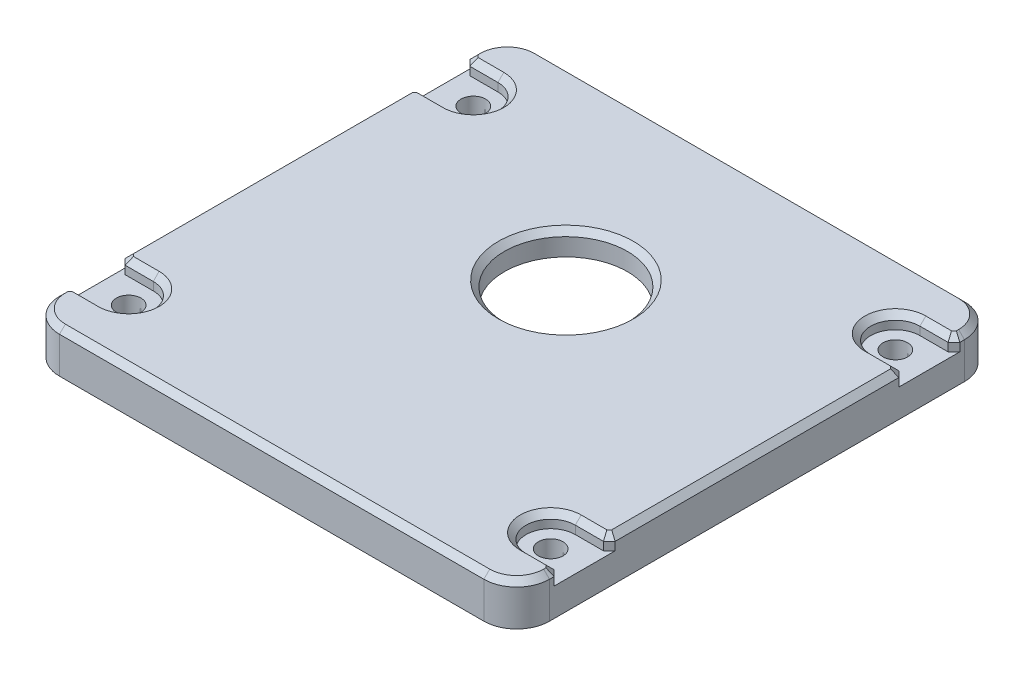
from build123d import *

# Parameters (mm, degrees)
SKETCH1_W           = 41.8
SKETCH1_H           = 41
SKETCH1_W_2         = 36.2
SKETCH1_H_2         = 37.4
BOSS_EXTRUDE1_DEPTH = 3
FILLET1_R           = 2.8
BOSS_EXTRUDE2_DEPTH = 0.6
BOSS_EXTRUDE3_DEPTH = 4.4
SKETCH5_R           = 1.05
CUT_EXTRUDE1_DEPTH  = 5.4
SKETCH6_W           = 31.1
SKETCH6_H           = 1.8
BOSS_EXTRUDE4_DEPTH = 4.4
FILLET2_R           = 1
SKETCH7_W           = 36.2
SKETCH7_H           = 37.4
SKETCH7_W_2         = 36
SKETCH7_H_2         = 37.2
CUT_EXTRUDE2_DEPTH  = 1.4
FILLET3_R           = 0.5
FILLET4_R           = 0.6
SKETCH8_R           = 1.05
SKETCH8_R_2         = 5.25
BOSS_EXTRUDE5_DEPTH = 2
CUT_EXTRUDE3_DEPTH  = 1.2
CHAMFER1_SIZE       = 0.5
CHAMFER2_SIZE       = 0.5


with BuildPart() as part:
    # Sketch1 → Boss-Extrude1 (new body)
    with BuildSketch(Plane(origin=(0, 0, 0), x_dir=(1, 0, 0), z_dir=(0, 1, 0))):
        Rectangle(SKETCH1_W, SKETCH1_H)
        Rectangle(SKETCH1_W_2, SKETCH1_H_2, mode=Mode.SUBTRACT)
    extrude(amount=BOSS_EXTRUDE1_DEPTH)

    # Fillet1
    fillet1_edges = [part.edges().sort_by_distance(p)[0] for p in [
        (20.9, 1.5, 20.5),
        (-20.9, 1.5, 20.5),
        (-20.9, 1.5, -20.5),
        (20.9, 1.5, -20.5),
    ]]
    fillet(fillet1_edges, radius=FILLET1_R)

    # Sketch2 → Boss-Extrude2 (add)
    with BuildSketch(Plane.XZ):
        with BuildLine():
            Line((20.9, -17.7), (20.9, 17.7))
            ThreePointArc((20.9, 17.7), (20.079898987, 19.679898987), (18.1, 20.5))
            Line((18.1, 20.5), (-18.1, 20.5))
            ThreePointArc((-18.1, 20.5), (-20.079898987, 19.679898987), (-20.9, 17.7))
            Line((-20.9, 17.7), (-20.9, -17.7))
            ThreePointArc((-20.9, -17.7), (-20.079898987, -19.679898987), (-18.1, -20.5))
            Line((-18.1, -20.5), (18.1, -20.5))
            ThreePointArc((18.1, -20.5), (20.079898987, -19.679898987), (20.9, -17.7))
        make_face()
        with BuildLine():
            Line((20.1, -17.7), (20.1, 17.7))
            ThreePointArc((20.1, 17.7), (19.514213562, 19.114213562), (18.1, 19.7))
            Line((18.1, 19.7), (-18.1, 19.7))
            ThreePointArc((-18.1, 19.7), (-19.514213562, 19.114213562), (-20.1, 17.7))
            Line((-20.1, 17.7), (-20.1, -17.7))
            ThreePointArc((-20.1, -17.7), (-19.514213562, -19.114213562), (-18.1, -19.7))
            Line((-18.1, -19.7), (18.1, -19.7))
            ThreePointArc((18.1, -19.7), (19.514213562, -19.114213562), (20.1, -17.7))
        make_face(mode=Mode.SUBTRACT)
    extrude(amount=BOSS_EXTRUDE2_DEPTH)

    # Sketch4 → Boss-Extrude3 (add)
    with BuildSketch(Plane(origin=(0, 3, 0), x_dir=(1, 0, 0), z_dir=(0, 1, 0))):
        with BuildLine():
            Line((-18, 15.75), (-18.1, 15.75))
            Line((-18.1, 15.75), (-18.1, 18.7))
            Line((-18.1, 18.7), (-15.55, 18.7))
            Line((-15.55, 18.7), (-15.55, 14.7))
            ThreePointArc((-15.55, 14.7), (-16.267588386, 12.967588386), (-18, 12.25))
            Line((-18, 12.25), (-18.1, 12.25))
            Line((-18.1, 12.25), (-18.1, 13.65))
            Line((-18.1, 13.65), (-18, 13.65))
            ThreePointArc((-18, 13.65), (-16.95, 14.7), (-18, 15.75))
        make_face()
        with BuildLine():
            Line((18.1, 15.75), (18.1, 18.7))
            Line((18.1, 18.7), (15.55, 18.7))
            Line((15.55, 18.7), (15.55, 14.7))
            ThreePointArc((15.55, 14.7), (16.267588386, 12.967588386), (18, 12.25))
            Line((18, 12.25), (18.1, 12.25))
            Line((18.1, 12.25), (18.1, 13.65))
            Line((18.1, 13.65), (18, 13.65))
            ThreePointArc((18, 13.65), (16.95, 14.7), (18, 15.75))
            Line((18, 15.75), (18.1, 15.75))
        make_face()
        with BuildLine():
            Line((18, -15.75), (18.1, -15.75))
            Line((18.1, -15.75), (18.1, -18.7))
            Line((18.1, -18.7), (15.55, -18.7))
            Line((15.55, -18.7), (15.55, -14.7))
            ThreePointArc((15.55, -14.7), (16.267588386, -12.967588386), (18, -12.25))
            Line((18, -12.25), (18.1, -12.25))
            Line((18.1, -12.25), (18.1, -13.65))
            Line((18.1, -13.65), (18, -13.65))
            ThreePointArc((18, -13.65), (16.95, -14.7), (18, -15.75))
        make_face()
        with BuildLine():
            Line((-18.1, -15.75), (-18.1, -18.7))
            Line((-18.1, -18.7), (-15.55, -18.7))
            Line((-15.55, -18.7), (-15.55, -14.7))
            ThreePointArc((-15.55, -14.7), (-16.267588386, -12.967588386), (-18, -12.25))
            Line((-18, -12.25), (-18.1, -12.25))
            Line((-18.1, -12.25), (-18.1, -13.65))
            Line((-18.1, -13.65), (-18, -13.65))
            ThreePointArc((-18, -13.65), (-16.95, -14.7), (-18, -15.75))
            Line((-18, -15.75), (-18.1, -15.75))
        make_face()
    extrude(amount=-BOSS_EXTRUDE3_DEPTH)

    # Sketch5 → Cut-Extrude1 (cut, through all)
    with BuildSketch(Plane(origin=(0, 3, 0), x_dir=(1, 0, 0), z_dir=(0, 1, 0))):
        with Locations((-18, 14.7)):
            Circle(SKETCH5_R)
        with Locations((18, 14.7)):
            Circle(SKETCH5_R)
        with Locations((18, -14.7)):
            Circle(SKETCH5_R)
        with Locations((-18, -14.7)):
            Circle(SKETCH5_R)
    extrude(amount=-CUT_EXTRUDE1_DEPTH, mode=Mode.SUBTRACT)

    # Sketch6 → Boss-Extrude4 (add)
    with BuildSketch(Plane(origin=(0, 3, 0), x_dir=(1, 0, 0), z_dir=(0, 1, 0))):
        with Locations((0, -17.8)):
            Rectangle(SKETCH6_W, SKETCH6_H)
        with Locations((0, 17.8)):
            Rectangle(SKETCH6_W, SKETCH6_H)
        with BuildLine():
            Line((-18.1, 12.25), (-18, 12.25))
            ThreePointArc((-18, 12.25), (-16.267588386, 12.967588386), (-15.55, 14.7))
            Line((-15.55, 14.7), (-15.55, 11.25))
            Line((-15.55, 11.25), (-18.1, 11.25))
            Line((-18.1, 11.25), (-18.1, 12.25))
        make_face()
        with BuildLine():
            Line((-15.55, -11.25), (-18.1, -11.25))
            Line((-18.1, -11.25), (-18.1, -12.25))
            Line((-18.1, -12.25), (-18, -12.25))
            ThreePointArc((-18, -12.25), (-16.267588386, -12.967588386), (-15.55, -14.7))
            Line((-15.55, -14.7), (-15.55, -11.25))
        make_face()
        with BuildLine():
            Line((15.55, -14.7), (15.55, -11.25))
            Line((15.55, -11.25), (18.1, -11.25))
            Line((18.1, -11.25), (18.1, -12.25))
            Line((18.1, -12.25), (18, -12.25))
            ThreePointArc((18, -12.25), (16.267588386, -12.967588386), (15.55, -14.7))
        make_face()
        with BuildLine():
            Line((15.55, 11.25), (18.1, 11.25))
            Line((18.1, 11.25), (18.1, 12.25))
            Line((18.1, 12.25), (18, 12.25))
            ThreePointArc((18, 12.25), (16.267588386, 12.967588386), (15.55, 14.7))
            Line((15.55, 14.7), (15.55, 11.25))
        make_face()
    extrude(amount=-BOSS_EXTRUDE4_DEPTH)

    # Fillet2
    fillet2_edges = [part.edges().sort_by_distance(p)[0] for p in [
        (15.55, 0.8, 16.9),
        (-15.55, 0.8, 16.9),
        (15.55, 0.8, -16.9),
        (-15.55, 0.8, -16.9),
        (-15.55, 0.8, 11.25),
        (-15.55, 0.8, -11.25),
        (15.55, 0.8, 11.25),
        (15.55, 0.8, -11.25),
    ]]
    fillet(fillet2_edges, radius=FILLET2_R)

    # Sketch7 → Cut-Extrude2 (cut)
    with BuildSketch(Plane.XZ.offset(1.4)):
        Rectangle(SKETCH7_W, SKETCH7_H)
        Rectangle(SKETCH7_W_2, SKETCH7_H_2, mode=Mode.SUBTRACT)
    extrude(amount=-CUT_EXTRUDE2_DEPTH, mode=Mode.SUBTRACT)

    # Fillet3
    fillet3_edges = [part.edges().sort_by_distance(p)[0] for p in [
        (-18, -0.7, -13.65),
        (-18, -0.7, -15.75),
        (18, -0.7, -15.75),
        (18, -0.7, -13.65),
        (18, -0.7, 13.65),
        (18, -0.7, 15.75),
        (-18, -0.7, 15.75),
        (-18, -0.7, 13.65),
        (18, -0.7, -11.25),
        (-18, -0.7, -11.25),
        (-18, -0.7, 18.6),
        (-18, -0.7, 11.25),
        (18, -0.7, -18.6),
        (18, -0.7, 11.25),
        (18, -0.7, 18.6),
        (-18, -0.7, -18.6),
    ]]
    fillet(fillet3_edges, radius=FILLET3_R)

    # Fillet4
    fillet4_edges = [part.edges().sort_by_distance(p)[0] for p in [
        (18.1, 1.5, -11.25),
        (-18.1, 1.5, -11.25),
        (-18.1, 1.5, 11.25),
        (18.1, 1.5, 11.25),
    ]]
    fillet(fillet4_edges, radius=FILLET4_R)

    # Sketch8 → Boss-Extrude5 (add)
    with BuildSketch(Plane(origin=(0, 3, 0), x_dir=(1, 0, 0), z_dir=(0, 1, 0))):
        with BuildLine():
            Line((-18.1, -20.5), (18.1, -20.5))
            ThreePointArc((18.1, -20.5), (20.079898987, -19.679898987), (20.9, -17.7))
            Line((20.9, -17.7), (20.9, 17.7))
            ThreePointArc((20.9, 17.7), (20.079898987, 19.679898987), (18.1, 20.5))
            Line((18.1, 20.5), (-18.1, 20.5))
            ThreePointArc((-18.1, 20.5), (-20.079898987, 19.679898987), (-20.9, 17.7))
            Line((-20.9, 17.7), (-20.9, -17.7))
            ThreePointArc((-20.9, -17.7), (-20.079898987, -19.679898987), (-18.1, -20.5))
        make_face()
        with Locations((-18, 14.7)):
            Circle(SKETCH8_R, mode=Mode.SUBTRACT)
        with Locations((18, 14.7)):
            Circle(SKETCH8_R, mode=Mode.SUBTRACT)
        with Locations((18, -14.7)):
            Circle(SKETCH8_R, mode=Mode.SUBTRACT)
        with Locations((-18, -14.7)):
            Circle(SKETCH8_R, mode=Mode.SUBTRACT)
        with Locations((0, 4.6)):
            Circle(SKETCH8_R_2, mode=Mode.SUBTRACT)
    extrude(amount=-BOSS_EXTRUDE5_DEPTH)

    # Sketch9 → Cut-Extrude3 (cut)
    with BuildSketch(Plane(origin=(0, 3, 0), x_dir=(1, 0, 0), z_dir=(0, 1, 0))):
        with BuildLine():
            Line((-18, 12.6), (-20.9, 12.6))
            ThreePointArc((-20.9, 12.6), (-23, 14.7), (-20.9, 16.8))
            Line((-20.9, 16.8), (-18, 16.8))
            ThreePointArc((-18, 16.8), (-15.9, 14.7), (-18, 12.6))
        make_face()
        with BuildLine():
            Line((18, 12.6), (20.9, 12.6))
            ThreePointArc((20.9, 12.6), (23, 14.7), (20.9, 16.8))
            Line((20.9, 16.8), (18, 16.8))
            ThreePointArc((18, 16.8), (15.9, 14.7), (18, 12.6))
        make_face()
        with BuildLine():
            Line((18, -12.6), (20.9, -12.6))
            ThreePointArc((20.9, -12.6), (23, -14.7), (20.9, -16.8))
            Line((20.9, -16.8), (18, -16.8))
            ThreePointArc((18, -16.8), (15.9, -14.7), (18, -12.6))
        make_face()
        with BuildLine():
            Line((-18, -12.6), (-20.9, -12.6))
            ThreePointArc((-20.9, -12.6), (-23, -14.7), (-20.9, -16.8))
            Line((-20.9, -16.8), (-18, -16.8))
            ThreePointArc((-18, -16.8), (-15.9, -14.7), (-18, -12.6))
        make_face()
    extrude(amount=-CUT_EXTRUDE3_DEPTH, mode=Mode.SUBTRACT)

    # Chamfer1
    chamfer1_edges = [part.edges().sort_by_distance(p)[0] for p in [
        (-20.9, 2.4, 16.8),
        (-20.9, 2.4, 12.6),
        (20.9, 2.4, 12.6),
        (20.9, 2.4, 16.8),
        (20.9, 2.4, -16.8),
        (20.9, 2.4, -12.6),
        (-20.9, 2.4, -12.6),
        (-20.9, 2.4, -16.8),
    ]]
    chamfer(chamfer1_edges, length=CHAMFER1_SIZE)

    # Chamfer2
    chamfer2_edges = [part.edges().sort_by_distance(p)[0] for p in [
        (-19.2, 3, 16.8),
        (-20.9, 3, 17.5),
        (19.2, 3, 12.6),
        (20.9, 3, 0),
        (19.2, 3, -16.8),
        (20.9, 3, -17.5),
        (-19.2, 3, -12.6),
        (-20.9, 3, 0),
        (-20.65, 3, -17.05),
        (-20.65, 3, -12.35),
        (20.65, 3, -17.05),
        (20.65, 3, -12.35),
        (20.65, 3, 12.35),
        (20.65, 3, 17.05),
        (-20.65, 3, 12.35),
        (-20.65, 3, 17.05),
        (20.9, 3, 17.5),
        (0, 3, 20.5),
        (0, 3, -20.5),
        (-20.9, 3, -17.5),
        (-20.079898987, 3, 19.679898987),
        (-20.079898987, 3, -19.679898987),
        (20.079898987, 3, -19.679898987),
        (20.079898987, 3, 19.679898987),
        (-5.25, 3, -4.6),
        (-15.9, 3, 14.7),
        (-19.2, 3, 12.6),
        (19.2, 3, 16.8),
        (15.9, 3, 14.7),
        (15.9, 3, -14.7),
        (19.2, 3, -12.6),
        (-19.2, 3, -16.8),
        (-15.9, 3, -14.7),
    ]]
    chamfer(chamfer2_edges, length=CHAMFER2_SIZE)


solid = part.part
